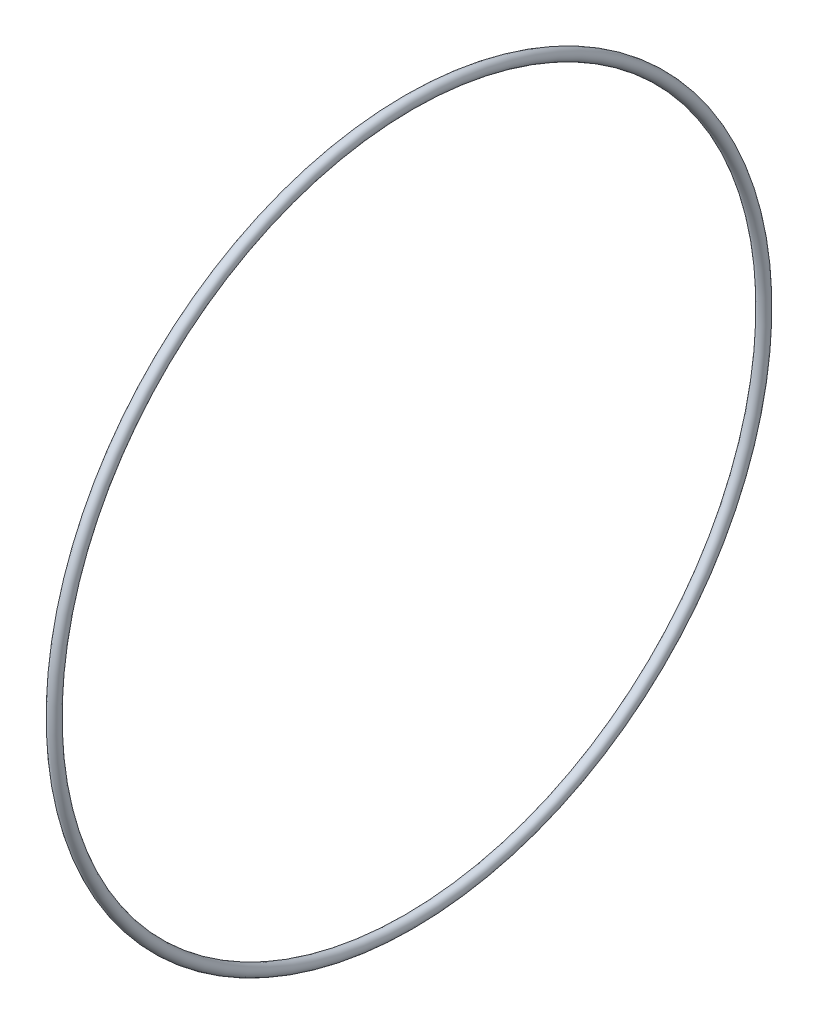
from build123d import *

# Parameters (mm, degrees)
SKETCH1_R   = 12.7
SKETCH1_R_2 = 10.31875


with BuildPart() as part:
    # Sketch1 → Revolve1 (revolve)
    with BuildSketch(Plane.XY):
        with Locations((0, 796.0995)):
            Circle(SKETCH1_R)
        with Locations((0, 796.0995)):
            Circle(SKETCH1_R_2, mode=Mode.SUBTRACT)
    revolve(axis=Axis((0, 0, 0), (1, 0, 0)))


solid = part.part
